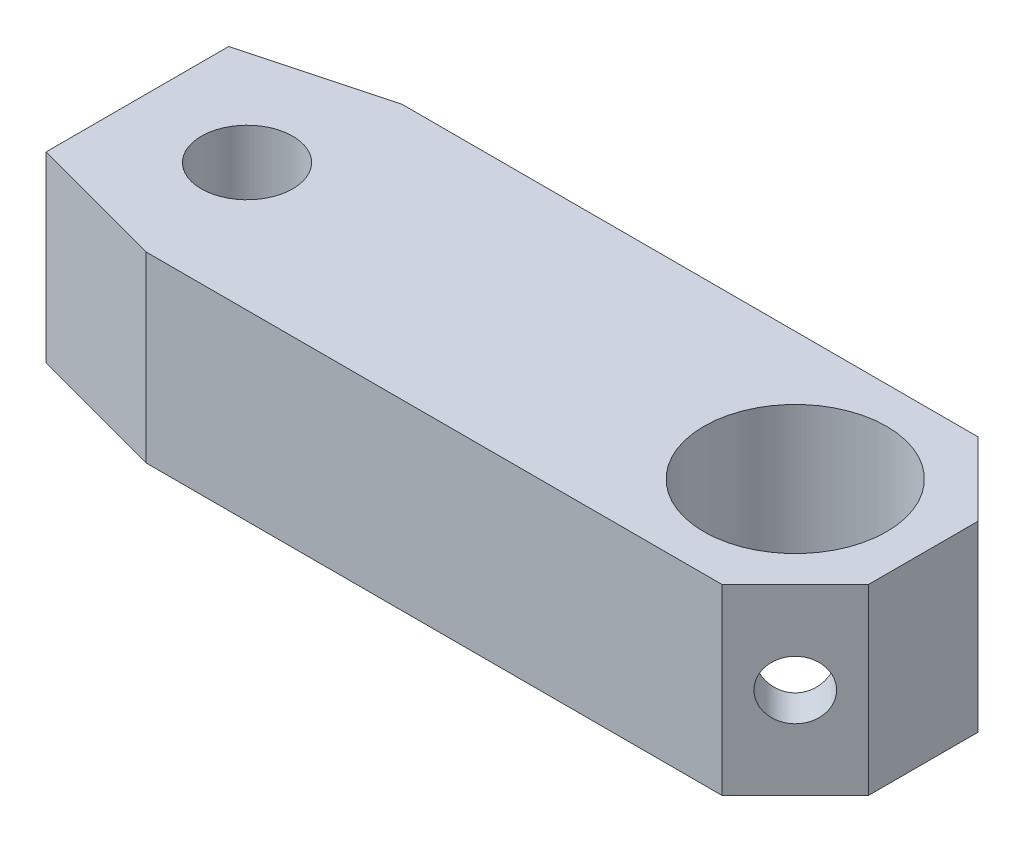
from build123d import *

# Parameters (mm, degrees)
BLOCK_R                = 2.5
BOSS_EXTRUDE1_DEPTH    = 5
M3_TAPPED_HOLE1_D      = 2.5
M2_TAPPED_HOLE1_REACH  = 21.397
M2_TAPPED_HOLE1_BORE_R = 0.8


with BuildPart() as part:
    # block → Boss-Extrude1 (new body)
    with BuildSketch(Plane(origin=(0, 0, 0), x_dir=(1, 0, 0), z_dir=(0, 1, 0))):
        Polygon((0.732050808, 3.5), (16.5, 3.5), (18.5, 1.5), (18.5, -1.5), (16.5, -3.5), (0.732050808, -3.5), (-3, -2.5), (-3, 2.5), align=None)
        with Locations(Location((15, 0, 0), (0, 0, 270))):
            Circle(BLOCK_R, mode=Mode.SUBTRACT)
    extrude(amount=-BOSS_EXTRUDE1_DEPTH)

    # M3 Tapped Hole1 (through all)
    with Locations(Plane(origin=(0, 0, 0), x_dir=(1, 0, 0), z_dir=(0, 1, 0))):
        with Locations((0, 0)):
            Hole(M3_TAPPED_HOLE1_D / 2)

    # M2 Tapped Hole1 bore → M2 Tapped Hole1 (cut, up to next)
    with BuildSketch(Plane(origin=(10, 0, -10), x_dir=(-0.7071067811865465, 0, -0.7071067811865486), z_dir=(0.7071067811865486, 0, -0.7071067811865465)), mode=Mode.PRIVATE) as m2_tapped_hole1_sk1:
        with Locations((-10.606601718, -2.5)):
            Circle(M2_TAPPED_HOLE1_BORE_R)
    m2_tapped_hole1_tool1 = extrude(m2_tapped_hole1_sk1.sketch, amount=-M2_TAPPED_HOLE1_REACH, mode=Mode.PRIVATE) & part.part
    m2_tapped_hole1 = m2_tapped_hole1_tool1.solids().sort_by_distance((17.5, -2.5, -2.5))[0]
    add(m2_tapped_hole1, mode=Mode.SUBTRACT)

    # Mirror1: M2 Tapped Hole1 across plane
    add(m2_tapped_hole1.mirror(Plane.XY), mode=Mode.SUBTRACT)


solid = part.part
